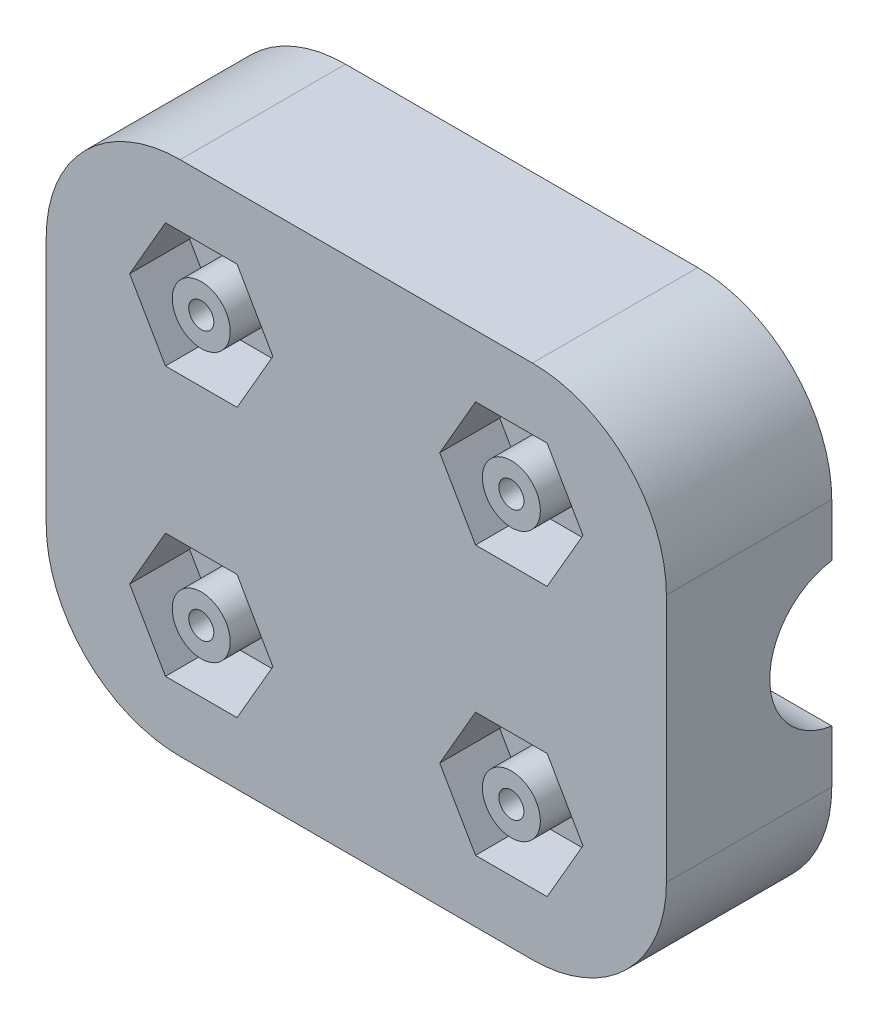
from build123d import *

# Parameters (mm, degrees)
BOSS_EXTRUDE2_DEPTH = 8
SKETCH10_R          = 1.800000439
CUT_EXTRUDE5_DEPTH  = 4.7
CUT_EXTRUDE6_DEPTH  = 2.9
SKETCH12_R          = 3.5
CUT_EXTRUDE7_DEPTH  = 31
SKETCH13_R          = 4
CUT_EXTRUDE8_DEPTH  = 15
SKETCH14_R          = 1.402200439
SKETCH14_R_2        = 0.606600439
BOSS_EXTRUDE3_DEPTH = 2.9


with BuildPart() as part:
    # Sketch9 → Boss-Extrude2 (new body)
    with BuildSketch(Plane.XY):
        with BuildLine():
            Line((15, -20.019238), (15, -7.980762))
            ThreePointArc((15, -7.980762), (13.101828757, -3.398171243), (8.519238, -1.5))
            Line((8.519238, -1.5), (-8.519238, -1.5))
            ThreePointArc((-8.519238, -1.5), (-13.101828757, -3.398171243), (-15, -7.980762))
            Line((-15, -7.980762), (-15, -20.019238))
            ThreePointArc((-15, -20.019238), (-13.101828757, -24.601828757), (-8.519238, -26.5))
            Line((-8.519238, -26.5), (8.519238, -26.5))
            ThreePointArc((8.519238, -26.5), (13.101828757, -24.601828757), (15, -20.019238))
        make_face()
    extrude(amount=-BOSS_EXTRUDE2_DEPTH)

    # Sketch10 → Cut-Extrude5 (cut)
    with BuildSketch(Plane(origin=(0, 0, -8), x_dir=(-1, 0, 0), z_dir=(0, 0, -1))):
        with Locations((-7.499999289, -7.499999745)):
            Circle(SKETCH10_R)
        with Locations((7.499999289, -7.499999745)):
            Circle(SKETCH10_R)
        with Locations((7.499999289, -20.500000255)):
            Circle(SKETCH10_R)
        with Locations((-7.499999289, -20.500000255)):
            Circle(SKETCH10_R)
    extrude(amount=-CUT_EXTRUDE5_DEPTH, mode=Mode.SUBTRACT)

    # Sketch11 → Cut-Extrude6 (cut)
    with BuildSketch(Plane.XY):
        Polygon((9.232050097, -4.499999745), (10.964100904, -7.499999745), (9.232050097, -10.499999745), (5.767948482, -10.499999745), (4.035897674, -7.499999745), (5.767948482, -4.499999745), align=None)
        Polygon((-9.232050097, -23.500000255), (-10.964100904, -20.500000255), (-9.232050097, -17.500000255), (-5.767948482, -17.500000255), (-4.035897674, -20.500000255), (-5.767948482, -23.500000255), align=None)
        Polygon((10.964100904, -20.500000255), (9.232050097, -17.500000255), (5.767948482, -17.500000255), (4.035897674, -20.500000255), (5.767948482, -23.500000255), (9.232050097, -23.500000255), align=None)
        Polygon((-10.964100904, -7.499999745), (-9.232050097, -10.499999745), (-5.767948482, -10.499999745), (-4.035897674, -7.499999745), (-5.767948482, -4.499999745), (-9.232050097, -4.499999745), align=None)
    extrude(amount=-CUT_EXTRUDE6_DEPTH, mode=Mode.SUBTRACT)

    # Sketch12 → Cut-Extrude7 (cut, through all)
    with BuildSketch(Plane(origin=(15, 0, 0), x_dir=(0, 0, -1), z_dir=(1, 0, 0))):
        with Locations((8.499999447, -14)):
            Circle(SKETCH12_R)
    extrude(amount=-CUT_EXTRUDE7_DEPTH, mode=Mode.SUBTRACT)

    # Sketch13 → Cut-Extrude8 (cut)
    with BuildSketch(Plane.ZY.offset(15)):
        with Locations((-8.499999973, -14)):
            Circle(SKETCH13_R)
    extrude(amount=-CUT_EXTRUDE8_DEPTH, mode=Mode.SUBTRACT)

    # Sketch14 → Boss-Extrude3 (add)
    with BuildSketch(Plane.XY.offset(-2.9)):
        with Locations((-7.499999289, -7.499999745)):
            Circle(SKETCH14_R)
        with Locations((-7.499999289, -7.499999745)):
            Circle(SKETCH14_R_2, mode=Mode.SUBTRACT)
        with Locations((7.499999289, -7.499999745)):
            Circle(SKETCH14_R)
        with Locations((7.499999289, -7.499999745)):
            Circle(SKETCH14_R_2, mode=Mode.SUBTRACT)
        with Locations((-7.499999289, -20.500000255)):
            Circle(SKETCH14_R)
        with Locations((-7.499999289, -20.500000255)):
            Circle(SKETCH14_R_2, mode=Mode.SUBTRACT)
        with Locations((7.499999289, -20.500000255)):
            Circle(SKETCH14_R)
        with Locations((7.499999289, -20.500000255)):
            Circle(SKETCH14_R_2, mode=Mode.SUBTRACT)
    extrude(amount=BOSS_EXTRUDE3_DEPTH)


solid = part.part
